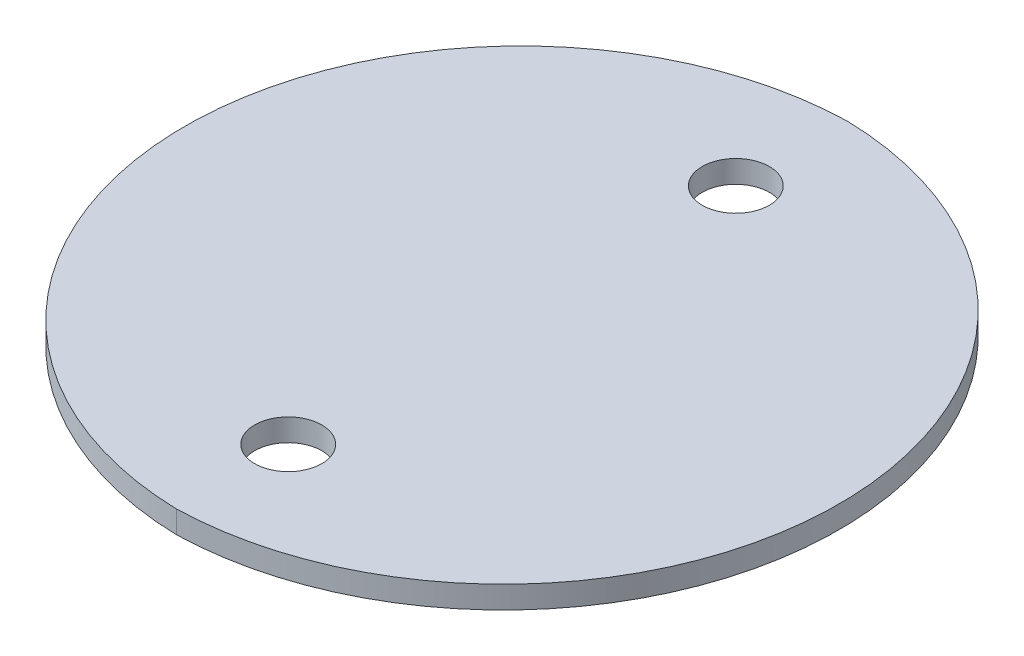
from build123d import *

# Parameters (mm, degrees)
SKETCH1_R           = 1.5
BOSS_EXTRUDE2_DEPTH = 1


with BuildPart() as part:
    # Sketch1 → Boss-Extrude2 (new body)
    with BuildSketch(Plane(origin=(0, 0, 0), x_dir=(1, 0, 0), z_dir=(0, 1, 0))):
        with BuildLine():
            ThreePointArc((0, 15), (-14.617669392, 0), (0, -15))
            ThreePointArc((0, -15), (14.617669392, 0), (0, 15))
        make_face()
        with Locations((0, 10)):
            Circle(SKETCH1_R, mode=Mode.SUBTRACT)
        with Locations((0, -10)):
            Circle(SKETCH1_R, mode=Mode.SUBTRACT)
    extrude(amount=BOSS_EXTRUDE2_DEPTH)


solid = part.part
